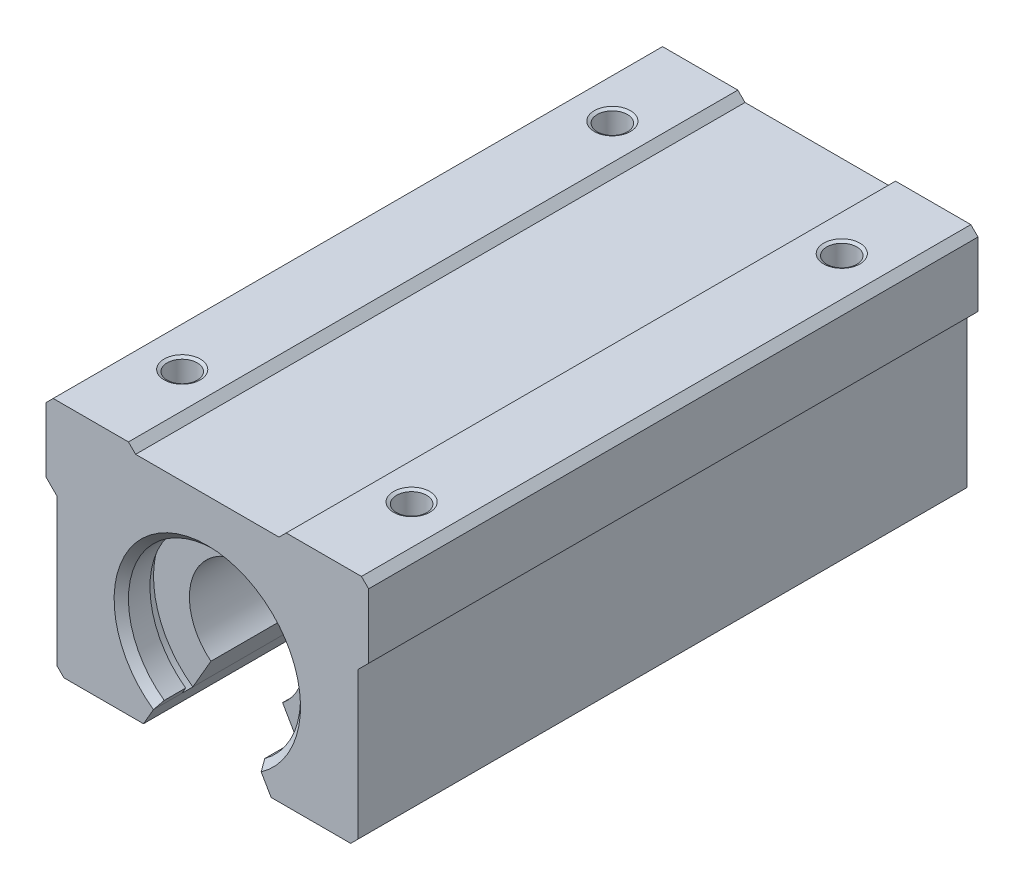
from build123d import *

# Parameters (mm, degrees)
BOSS_EXTRUDE1_DEPTH         = 85
CHAMFER2_SIZE               = 1
CHAMFER3_SIZE               = 1
M5_TAPPED_HOLE1_D           = 4.2
M5_TAPPED_HOLE1_DEPTH       = 12
M5_TAPPED_HOLE1_CSINK_D     = 5.05
M5_TAPPED_HOLE1_CSINK_ANGLE = 120
M5_TAPPED_HOLE1_TIP         = 1.2618073
SKETCH6_R                   = 12
CUT_EXTRUDE1_DEPTH          = 4
SKETCH7_R                   = 12
CUT_EXTRUDE2_DEPTH          = 4
CHAMFER5_SIZE               = 1
SKETCH12_R                  = 13
CUT_EXTRUDE7_DEPTH          = 1.5
SKETCH13_R                  = 13
CUT_EXTRUDE8_DEPTH          = 1.5


with BuildPart() as part:
    # Sketch1 → Boss-Extrude1 (new body)
    with BuildSketch(Plane.XY):
        with BuildLine():
            Line((10, 19), (-10, 19))
            Line((-10, 19), (-11, 20))
            Line((-11, 20), (-22.5, 20))
            Line((-22.5, 20), (-22.5, 10))
            Line((-22.5, 10), (-21, 8.5))
            Line((-21, 8.5), (-21, -13))
            Line((-21, -13), (-8.9, -13))
            Line((-8.9, -13), (-4.999998479, -6.244999216))
            ThreePointArc((-4.999998479, -6.244999216), (0, 8), (4.999998479, -6.244999216))
            Line((4.999998479, -6.244999216), (8.9, -13))
            Line((8.9, -13), (21, -13))
            Line((21, -13), (21, 8.5))
            Line((21, 8.5), (22.5, 10))
            Line((22.5, 10), (22.5, 20))
            Line((22.5, 20), (11, 20))
            Line((11, 20), (10, 19))
        make_face()
    extrude(amount=BOSS_EXTRUDE1_DEPTH)

    # Chamfer2
    chamfer2_edges = [part.edges().sort_by_distance(p)[0] for p in [
        (-22.5, 20, 42.5),
    ]]
    chamfer(chamfer2_edges, length=CHAMFER2_SIZE)

    # Chamfer3
    chamfer3_edges = [part.edges().sort_by_distance(p)[0] for p in [
        (-21, -13, 42.5),
        (22.5, 20, 42.5),
        (21, -13, 42.5),
    ]]
    chamfer(chamfer3_edges, length=CHAMFER3_SIZE)

    # M5 Tapped Hole1
    with Locations(Plane(origin=(-16, 20, 12.5), x_dir=(0, 0, 1), z_dir=(0, 1, 0))):
        with Locations((0, 0), (0, 32), (60, 0), (60, 32)):
            CounterSinkHole(M5_TAPPED_HOLE1_D / 2, M5_TAPPED_HOLE1_CSINK_D / 2, depth=M5_TAPPED_HOLE1_DEPTH, counter_sink_angle=M5_TAPPED_HOLE1_CSINK_ANGLE)
            with Locations((0, 0, -(M5_TAPPED_HOLE1_DEPTH + M5_TAPPED_HOLE1_TIP / 2))):  # 118° drill point
                Cone(0, M5_TAPPED_HOLE1_D / 2, M5_TAPPED_HOLE1_TIP, mode=Mode.SUBTRACT)

    # Sketch6 → Cut-Extrude1 (cut)
    with BuildSketch(Plane.XY.offset(85)):
        Circle(SKETCH6_R)
    extrude(amount=-CUT_EXTRUDE1_DEPTH, mode=Mode.SUBTRACT)

    # Sketch7 → Cut-Extrude2 (cut)
    with BuildSketch(Plane(origin=(0, 0, 0), x_dir=(-1, 0, 0), z_dir=(0, 0, -1))):
        Circle(SKETCH7_R)
    extrude(amount=-CUT_EXTRUDE2_DEPTH, mode=Mode.SUBTRACT)

    # Chamfer5
    chamfer5_edges = [part.edges().sort_by_distance(p)[0] for p in [
        (0, 12, 0),
        (0, 12, 85),
    ]]
    chamfer(chamfer5_edges, length=CHAMFER5_SIZE)

    # Sketch12 → Cut-Extrude7 (cut)
    with BuildSketch(Plane.XY.offset(81)):
        Circle(SKETCH12_R)
    extrude(amount=-CUT_EXTRUDE7_DEPTH, mode=Mode.SUBTRACT)

    # Sketch13 → Cut-Extrude8 (cut)
    with BuildSketch(Plane(origin=(0, 0, 4), x_dir=(-1, 0, 0), z_dir=(0, 0, -1))):
        Circle(SKETCH13_R)
    extrude(amount=-CUT_EXTRUDE8_DEPTH, mode=Mode.SUBTRACT)


solid = part.part
